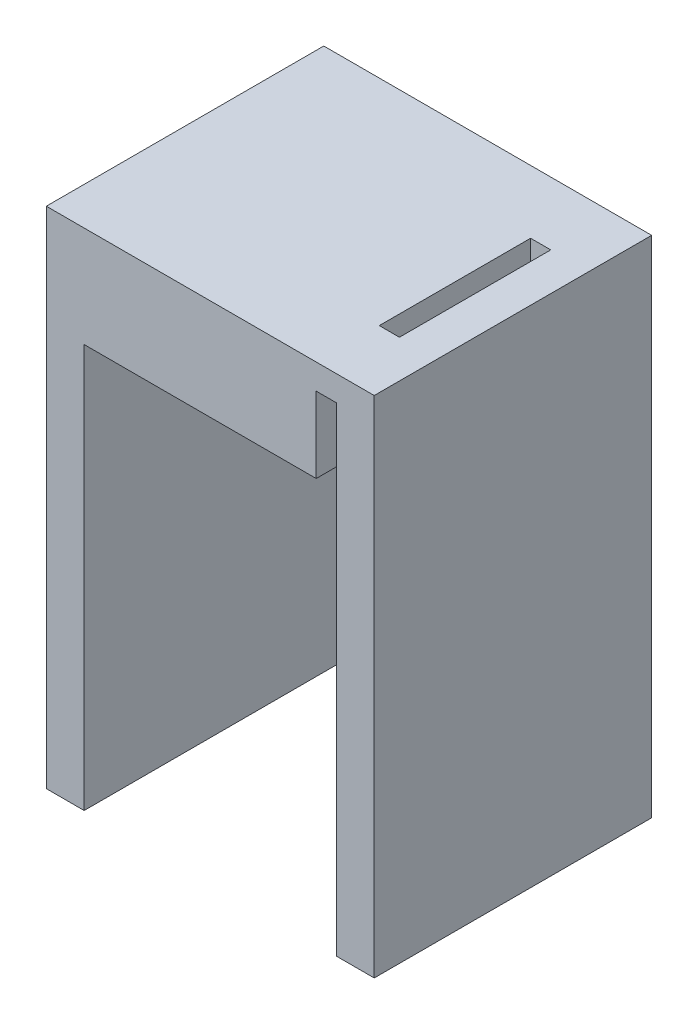
from build123d import *

# Parameters (mm, degrees)
BOSS_EXTRUDE1_DEPTH = 13.97
SKETCH3_W           = 1.016
SKETCH3_H           = 3.81
CUT_EXTRUDE1_DEPTH  = 14.97
CUT_EXTRUDE2_DEPTH  = 2.27


with BuildPart() as part:
    # Sketch1 → Boss-Extrude1 (new body)
    with BuildSketch(Plane.XY):
        Polygon((0, 0), (0, 20.32), (-12.7, 20.32), (-12.7, 0), (-14.605, 0), (-14.605, 19.05), (-14.605, 25.4), (1.905, 25.4), (1.905, 19.05), (1.905, 0), align=None)
    extrude(amount=-BOSS_EXTRUDE1_DEPTH)

    # Sketch3 → Cut-Extrude1 (cut, through all)
    with BuildSketch(Plane.XY):
        with Locations((-0.508, 22.225)):
            Rectangle(SKETCH3_W, SKETCH3_H)
    extrude(amount=-CUT_EXTRUDE1_DEPTH, mode=Mode.SUBTRACT)

    # Sketch4 → Cut-Extrude2 (cut, through all)
    with BuildSketch(Plane.XZ.offset(-24.13)):
        Polygon((-1.016, -6.985), (-1.016, -3.175), (0, -3.175), (0, -10.795), (-1.016, -10.795), align=None)
    extrude(amount=-CUT_EXTRUDE2_DEPTH, mode=Mode.SUBTRACT)


solid = part.part
